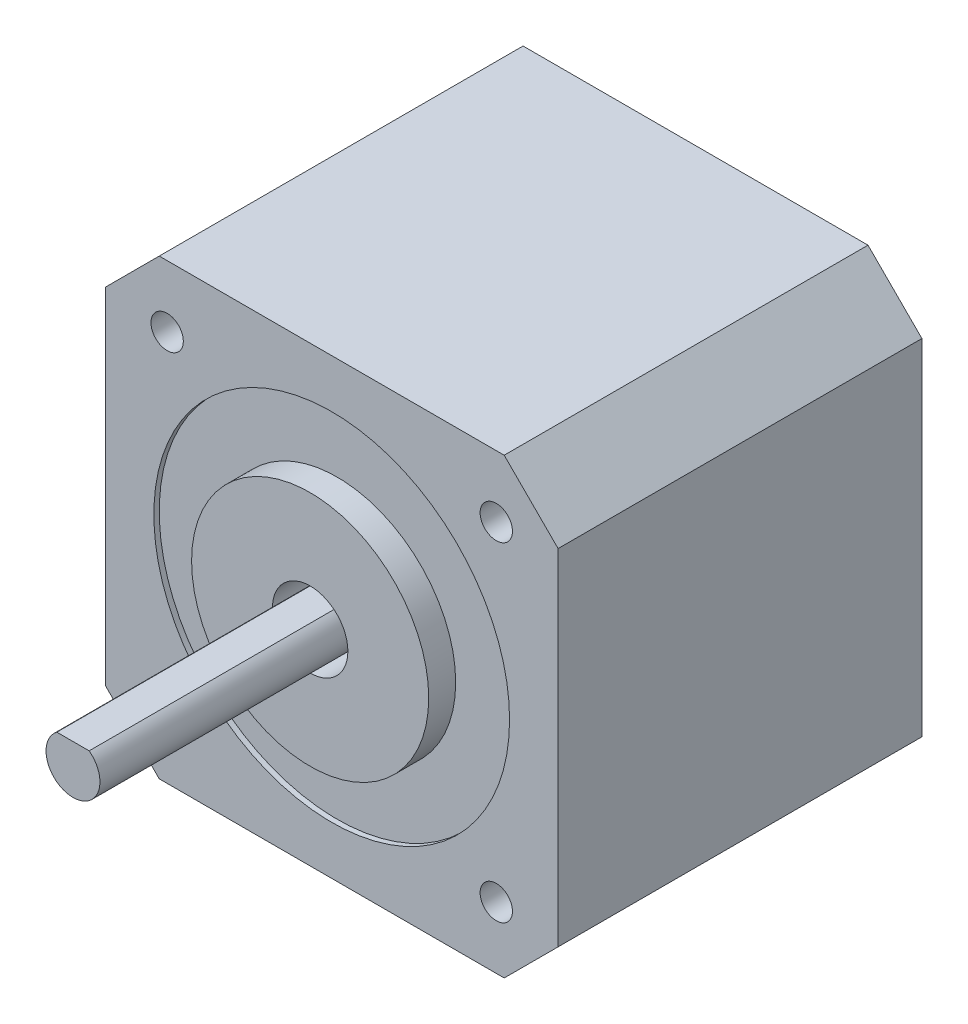
from build123d import *

# Parameters (mm, degrees)
BOSS_EXTRUDE1_DEPTH = 33.75
SKETCH2_R           = 16.5
CUT_EXTRUDE1_DEPTH  = 0.5
SKETCH3_R           = 11
BOSS_EXTRUDE2_DEPTH = 2.5
SKETCH4_R           = 3.5
CUT_EXTRUDE2_DEPTH  = 5
BOSS_EXTRUDE3_DEPTH = 27
SKETCH6_R           = 1.5
CUT_EXTRUDE3_DEPTH  = 5


with BuildPart() as part:
    # Sketch1 → Boss-Extrude1 (new body)
    with BuildSketch(Plane.XY):
        Polygon((-34.980846502, 45.63851346), (-39.980846502, 40.63851346), (-39.980846502, 8.63851346), (-34.980846502, 3.63851346), (-2.980846502, 3.63851346), (2.019153498, 8.63851346), (2.019153498, 40.63851346), (-2.980846502, 45.63851346), align=None)
    extrude(amount=BOSS_EXTRUDE1_DEPTH)

    # Sketch2 → Cut-Extrude1 (cut)
    with BuildSketch(Plane.XY.offset(33.75)):
        with Locations((-18.980846502, 24.63851346)):
            Circle(SKETCH2_R)
    extrude(amount=-CUT_EXTRUDE1_DEPTH, mode=Mode.SUBTRACT)

    # Sketch3 → Boss-Extrude2 (add)
    with BuildSketch(Plane.XY.offset(33.25)):
        with Locations((-18.980846502, 24.63851346)):
            Circle(SKETCH3_R)
    extrude(amount=BOSS_EXTRUDE2_DEPTH)

    # Sketch4 → Cut-Extrude2 (cut)
    with BuildSketch(Plane.XY.offset(35.75)):
        with Locations((-18.980846502, 24.63851346)):
            Circle(SKETCH4_R)
    extrude(amount=-CUT_EXTRUDE2_DEPTH, mode=Mode.SUBTRACT)

    # Sketch5 → Boss-Extrude3 (add)
    with BuildSketch(Plane.XY.offset(30.75)):
        with BuildLine():
            Line((-20.480846502, 26.63851346), (-17.480846502, 26.63851346))
            ThreePointArc((-17.480846502, 26.63851346), (-18.980846502, 22.13851346), (-20.480846502, 26.63851346))
        make_face()
    extrude(amount=BOSS_EXTRUDE3_DEPTH)

    # Sketch6 → Cut-Extrude3 (cut)
    with BuildSketch(Plane.XY.offset(33.75)):
        with Locations((-34.247281908, 39.904948866)):
            Circle(SKETCH6_R)
        with Locations((-3.714411096, 39.904948866)):
            Circle(SKETCH6_R)
        with Locations((-3.714411096, 9.372078054)):
            Circle(SKETCH6_R)
        with Locations((-34.247281908, 9.372078054)):
            Circle(SKETCH6_R)
    cut_extrude3 = extrude(amount=-CUT_EXTRUDE3_DEPTH, mode=Mode.SUBTRACT)

    # Mirror1: Cut-Extrude3 across plane
    add(cut_extrude3.mirror(Plane(origin=(0, 0, 16.875), x_dir=(1, 0, 0), z_dir=(0, 0, -1))), mode=Mode.SUBTRACT)


solid = part.part
